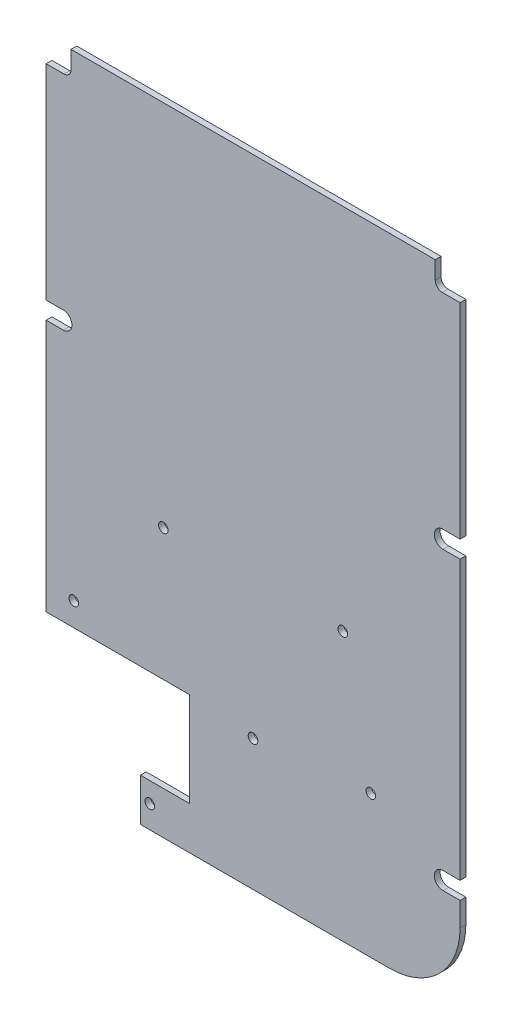
from build123d import *

# Parameters (mm, degrees)
SKETCH_1_R          = 1.025
EXTRUDE_1_DEPTH     = 1.23
SKETCH_2_W          = 5.3
SKETCH_2_H          = 5.3
CUT_EXTRUDE_1_DEPTH = 10
FILLET_1_R          = 1.5


with BuildPart() as part:
    # 草图1 → 凸台-拉伸1 (new body)
    with BuildSketch(Plane.XY):
        with BuildLine():
            Line((44.125, 15.2), (44.125, -44.1))
            Line((44.125, -44.1), (40.475, -44.1))
            ThreePointArc((40.475, -44.1), (38.625, -45.95), (40.475, -47.8))
            Line((40.475, -47.8), (44.125, -47.8))
            Line((44.125, -47.8), (44.125, -52.85))
            ThreePointArc((44.125, -52.85), (39.731601718, -63.456601718), (29.125, -67.85))
            Line((29.125, -67.85), (-24.025, -67.85))
            Line((-24.025, -67.85), (-24.025, -58.75))
            Line((-24.025, -58.75), (-13.525, -58.75))
            Line((-13.525, -58.75), (-13.525, -38.65))
            Line((-13.525, -38.65), (-44.125, -38.65))
            Line((-44.125, -38.65), (-44.125, 15.2))
            Line((-44.125, 15.2), (-40.475, 15.2))
            ThreePointArc((-40.475, 15.2), (-38.625, 17.05), (-40.475, 18.9))
            Line((-40.475, 18.9), (-44.125, 18.9))
            Line((-44.125, 18.9), (-44.125, 67.85))
            Line((-44.125, 67.85), (44.125, 67.85))
            Line((44.125, 67.85), (44.125, 18.9))
            Line((44.125, 18.9), (40.475, 18.9))
            ThreePointArc((40.475, 18.9), (38.625, 17.05), (40.475, 15.2))
            Line((40.475, 15.2), (44.125, 15.2))
        make_face()
        with Locations((-22.025, -63)):
            Circle(SKETCH_1_R, mode=Mode.SUBTRACT)
        with Locations((-19.125, -10.6)):
            Circle(SKETCH_1_R, mode=Mode.SUBTRACT)
        with Locations((-0.025, -39.95)):
            Circle(SKETCH_1_R, mode=Mode.SUBTRACT)
        with Locations((-38.225, -33.65)):
            Circle(SKETCH_1_R, mode=Mode.SUBTRACT)
        with Locations((25.075, -37.55)):
            Circle(SKETCH_1_R, mode=Mode.SUBTRACT)
        with Locations((19.125, -10.6)):
            Circle(SKETCH_1_R, mode=Mode.SUBTRACT)
    extrude(amount=EXTRUDE_1_DEPTH)

    # 草图2 → 切除-拉伸1 (cut)
    with BuildSketch(Plane.XY.offset(1.23)):
        with Locations((-41.475, 65.2)):
            Rectangle(SKETCH_2_W, SKETCH_2_H)
        with Locations((41.475, 65.2)):
            Rectangle(SKETCH_2_W, SKETCH_2_H)
    extrude(amount=-CUT_EXTRUDE_1_DEPTH, mode=Mode.SUBTRACT)

    # 圆角1
    fillet_1_edges = [part.edges().sort_by_distance(p)[0] for p in [
        (-38.825, 62.55, 0.615),
        (38.825, 62.55, 0.615),
    ]]
    fillet(fillet_1_edges, radius=FILLET_1_R)


solid = part.part
